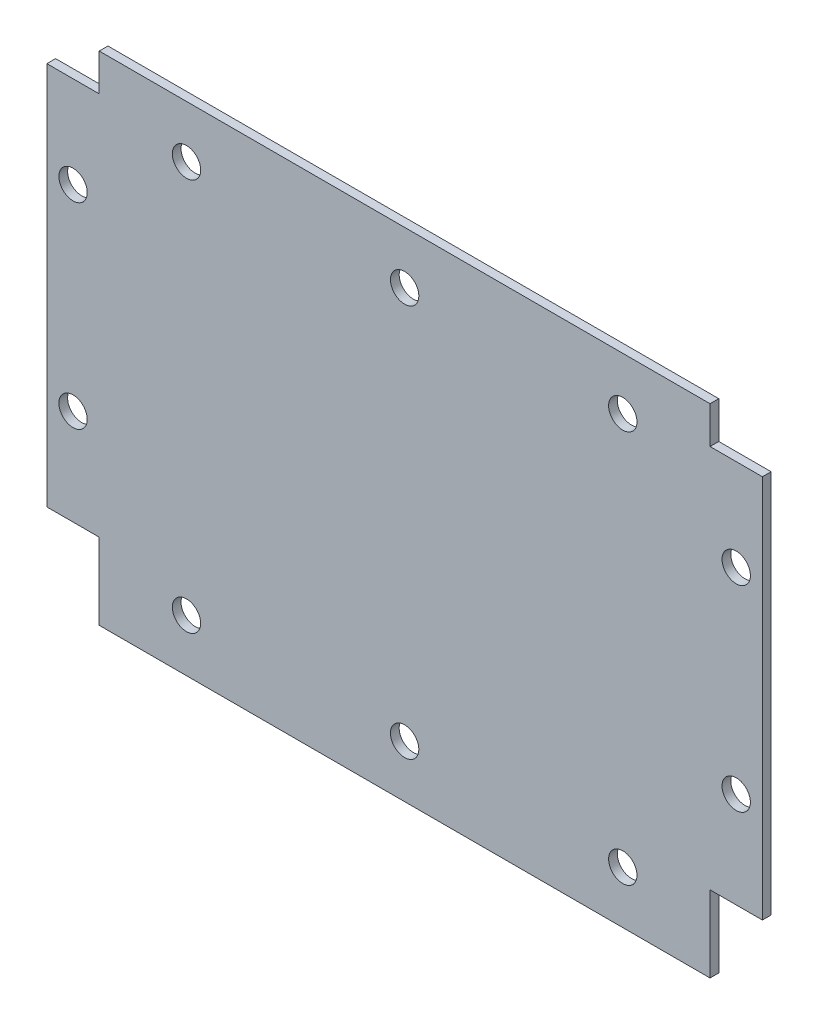
from build123d import *

# Parameters (mm, degrees)
EXTRUDE_1_DEPTH   = 2
HOLE_WIZARD_M61_D = 6.5


with BuildPart() as part:
    # Эскиз1 → Вытянуть1 (new body)
    with BuildSketch(Plane.XY):
        Polygon((-70, 48.5), (-70, 57), (70, 57), (70, 48.5), (82, 48.5), (82, -39.5), (70, -39.5), (70, -57), (-70, -57), (-70, -39.5), (-82, -39.5), (-82, 48.5), align=None)
    extrude(amount=EXTRUDE_1_DEPTH)

    # Отверстие с зазором M61 (through all)
    with Locations(Plane(origin=(-76, 27.5, 2), x_dir=(1, 0, 0), z_dir=(0, 0, 1))):
        with Locations((0, 0), (0, -45), (26, -72.5), (76, -72.5), (126, -72.5), (126, 17.5), (76, 17.5), (26, 17.5), (152, 0), (152, -45)):
            Hole(HOLE_WIZARD_M61_D / 2)


solid = part.part
